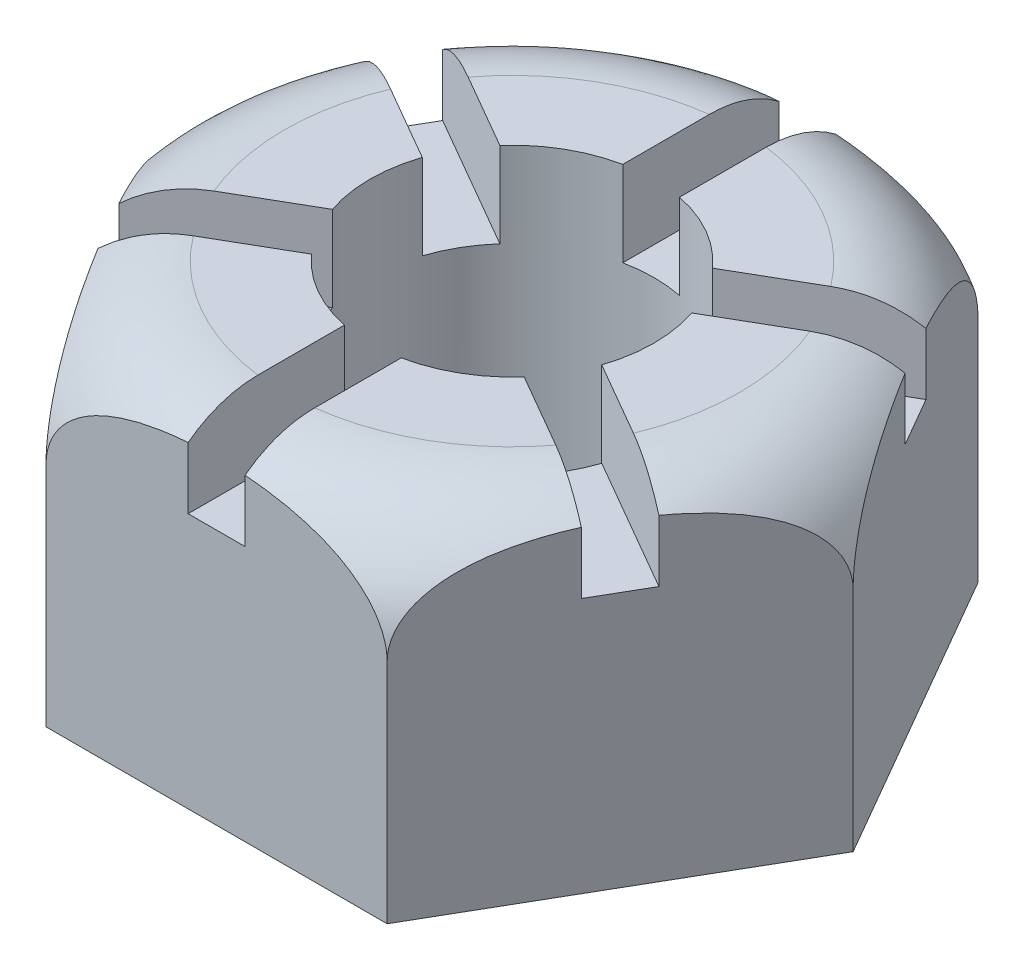
from build123d import *

# Parameters (mm, degrees)
SKETCH1_R           = 25
BOSS_EXTRUDE1_DEPTH = 60
CUT_EXTRUDE1_REACH  = 107
CUT_EXTRUDE1_START  = 45


with BuildPart() as part:
    # Sketch1 → Boss-Extrude1 (new body)
    with BuildSketch(Plane(origin=(0, 0, 0), x_dir=(1, 0, 0), z_dir=(0, 1, 0))):
        Polygon((60.044427996, 0), (30.022213998, 52), (-30.022213998, 52), (-60.044427996, 0), (-30.022213998, -52), (30.022213998, -52), align=None)
        Circle(SKETCH1_R, mode=Mode.SUBTRACT)
    extrude(amount=BOSS_EXTRUDE1_DEPTH)

    # Sketch2 → Cut-Extrude1 (cut, up to next)
    with BuildSketch(Plane(origin=(0, 0, 0), x_dir=(1, 0, 0), z_dir=(0, 1, 0)).offset(CUT_EXTRUDE1_START), mode=Mode.PRIVATE) as cut_extrude1_sk1:
        with BuildLine():
            Line((-47.533320997, -21.669872981), (-42.533320997, -30.330127019))
            Line((-42.533320997, -30.330127019), (-18.713203436, -16.577575733))
            ThreePointArc((-18.713203436, -16.577575733), (-21.650635095, -12.5), (-23.713203436, -7.917321695))
            Line((-23.713203436, -7.917321695), (-47.533320997, -21.669872981))
        make_face()
    cut_extrude1_tool1 = extrude(cut_extrude1_sk1.sketch, amount=CUT_EXTRUDE1_REACH, mode=Mode.PRIVATE) & part.part
    add(cut_extrude1_tool1.solids().sort_by_distance((-33.26901, 45, 19.207872))[0], mode=Mode.SUBTRACT)
    # Sketch2 → Cut-Extrude1 (cut, up to next)
    with BuildSketch(Plane(origin=(0, 0, 0), x_dir=(1, 0, 0), z_dir=(0, 1, 0)).offset(CUT_EXTRUDE1_START), mode=Mode.PRIVATE) as cut_extrude1_sk2:
        with BuildLine():
            Line((-5, -52), (5, -52))
            Line((5, -52), (5, -24.494897428))
            ThreePointArc((5, -24.494897428), (0, -25), (-5, -24.494897428))
            Line((-5, -24.494897428), (-5, -52))
        make_face()
    cut_extrude1_tool2 = extrude(cut_extrude1_sk2.sketch, amount=CUT_EXTRUDE1_REACH, mode=Mode.PRIVATE) & part.part
    add(cut_extrude1_tool2.solids().sort_by_distance((0, 45, 38.415743))[0], mode=Mode.SUBTRACT)
    # Sketch2 → Cut-Extrude1 (cut, up to next)
    with BuildSketch(Plane(origin=(0, 0, 0), x_dir=(1, 0, 0), z_dir=(0, 1, 0)).offset(CUT_EXTRUDE1_START), mode=Mode.PRIVATE) as cut_extrude1_sk3:
        with BuildLine():
            Line((42.533320997, -30.330127019), (47.533320997, -21.669872981))
            Line((47.533320997, -21.669872981), (23.713203436, -7.917321695))
            ThreePointArc((23.713203436, -7.917321695), (21.650635095, -12.5), (18.713203436, -16.577575733))
            Line((18.713203436, -16.577575733), (42.533320997, -30.330127019))
        make_face()
    cut_extrude1_tool3 = extrude(cut_extrude1_sk3.sketch, amount=CUT_EXTRUDE1_REACH, mode=Mode.PRIVATE) & part.part
    add(cut_extrude1_tool3.solids().sort_by_distance((33.26901, 45, 19.207872))[0], mode=Mode.SUBTRACT)
    # Sketch2 → Cut-Extrude1 (cut, up to next)
    with BuildSketch(Plane(origin=(0, 0, 0), x_dir=(1, 0, 0), z_dir=(0, 1, 0)).offset(CUT_EXTRUDE1_START), mode=Mode.PRIVATE) as cut_extrude1_sk4:
        with BuildLine():
            Line((47.533320997, 21.669872981), (42.533320997, 30.330127019))
            Line((42.533320997, 30.330127019), (18.713203436, 16.577575733))
            ThreePointArc((18.713203436, 16.577575733), (21.650635095, 12.5), (23.713203436, 7.917321695))
            Line((23.713203436, 7.917321695), (47.533320997, 21.669872981))
        make_face()
    cut_extrude1_tool4 = extrude(cut_extrude1_sk4.sketch, amount=CUT_EXTRUDE1_REACH, mode=Mode.PRIVATE) & part.part
    add(cut_extrude1_tool4.solids().sort_by_distance((33.26901, 45, -19.207872))[0], mode=Mode.SUBTRACT)
    # Sketch2 → Cut-Extrude1 (cut, up to next)
    with BuildSketch(Plane(origin=(0, 0, 0), x_dir=(1, 0, 0), z_dir=(0, 1, 0)).offset(CUT_EXTRUDE1_START), mode=Mode.PRIVATE) as cut_extrude1_sk5:
        with BuildLine():
            Line((5, 52), (-5, 52))
            Line((-5, 52), (-5, 24.494897428))
            ThreePointArc((-5, 24.494897428), (0, 25), (5, 24.494897428))
            Line((5, 24.494897428), (5, 52))
        make_face()
    cut_extrude1_tool5 = extrude(cut_extrude1_sk5.sketch, amount=CUT_EXTRUDE1_REACH, mode=Mode.PRIVATE) & part.part
    add(cut_extrude1_tool5.solids().sort_by_distance((0, 45, -38.415743))[0], mode=Mode.SUBTRACT)
    # Sketch2 → Cut-Extrude1 (cut, up to next)
    with BuildSketch(Plane(origin=(0, 0, 0), x_dir=(1, 0, 0), z_dir=(0, 1, 0)).offset(CUT_EXTRUDE1_START), mode=Mode.PRIVATE) as cut_extrude1_sk6:
        with BuildLine():
            Line((-42.533320997, 30.330127019), (-47.533320997, 21.669872981))
            Line((-47.533320997, 21.669872981), (-23.713203436, 7.917321695))
            ThreePointArc((-23.713203436, 7.917321695), (-21.650635095, 12.5), (-18.713203436, 16.577575733))
            Line((-18.713203436, 16.577575733), (-42.533320997, 30.330127019))
        make_face()
    cut_extrude1_tool6 = extrude(cut_extrude1_sk6.sketch, amount=CUT_EXTRUDE1_REACH, mode=Mode.PRIVATE) & part.part
    add(cut_extrude1_tool6.solids().sort_by_distance((-33.26901, 45, -19.207872))[0], mode=Mode.SUBTRACT)

    # Sketch3 → Cut-Revolve1 (revolve, cut)
    with BuildSketch(Plane.XY):
        with BuildLine():
            Line((60.044427996, 40), (60.044427996, 60))
            Line((60.044427996, 60), (40.044427996, 60))
            ThreePointArc((40.044427996, 60), (54.186563619, 54.142135624), (60.044427996, 40))
        make_face()
    revolve(axis=Axis((0, 0, 0), (0, -1, 0)), mode=Mode.SUBTRACT)


solid = part.part
